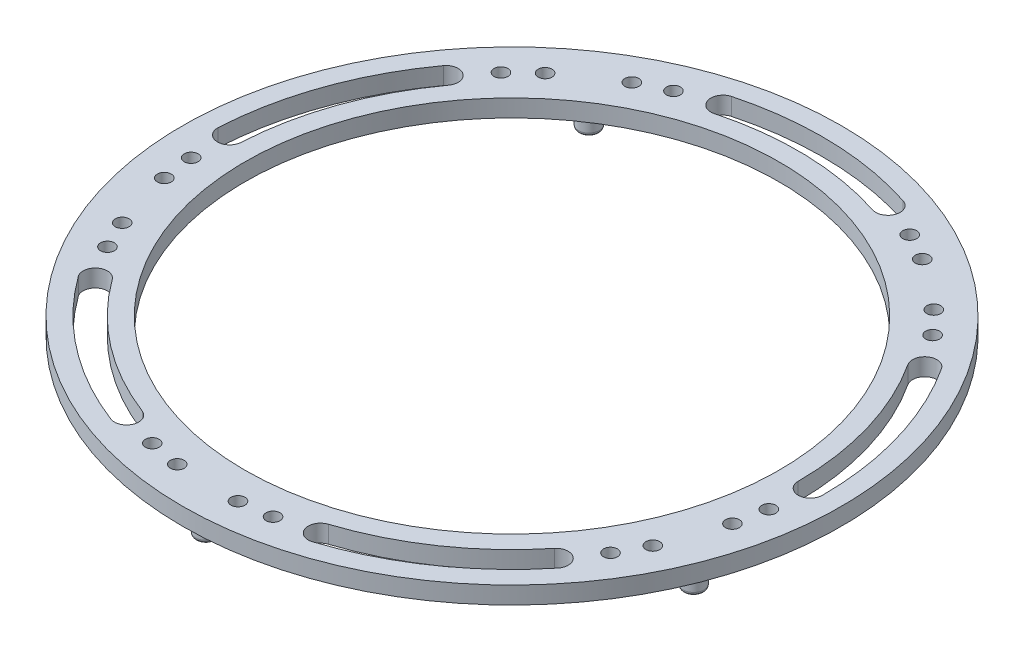
from build123d import *

# Parameters (mm, degrees)
SKETCH1_R                = 47.5
SKETCH1_R_2              = 38.5
BOSS_EXTRUDE1_DEPTH      = 2.5
SKETCH2_R                = 1.5
CUT_EXTRUDE1_DEPTH       = 2.5
SKETCH3_R                = 1.5
BOSS_EXTRUDE2_DEPTH      = 6.5
FILLET1_R                = 0.5
CIRPATTERN1_COUNT        = 5
FILLET1_OF_CIRPATTERN1_R = 0.5
SKETCH4_R                = 1
CUT_EXTRUDE2_DEPTH       = 2.5
CIRPATTERN2_COUNT        = 5


with BuildPart() as part:
    # Sketch1 → Boss-Extrude1 (new body)
    with BuildSketch(Plane(origin=(0, 0, 0), x_dir=(1, 0, 0), z_dir=(0, 1, 0))):
        Circle(SKETCH1_R)
        Circle(SKETCH1_R_2, mode=Mode.SUBTRACT)
    extrude(amount=BOSS_EXTRUDE1_DEPTH)

    # Sketch2 → Cut-Extrude1 (cut)
    with BuildSketch(Plane(origin=(0, 2.5, 0), x_dir=(1, 0, 0), z_dir=(0, 1, 0))):
        with Locations((26.176741447, 34.114193633)):
            Circle(SKETCH2_R)
        with BuildLine():
            ThreePointArc((44.75, 0), (42.907183135, 12.709686676), (37.530507916, 24.372596817))
            ThreePointArc((37.530507916, 24.372596817), (35.10971611, 24.887152), (34.595160928, 22.466360194))
            ThreePointArc((34.595160928, 22.466360194), (39.551314063, 11.715632969), (41.25, 0))
            ThreePointArc((41.25, 0), (43, -1.75), (44.75, 0))
        make_face()
    cut_extrude1 = extrude(amount=-CUT_EXTRUDE1_DEPTH, mode=Mode.SUBTRACT)

    # Sketch3 → Boss-Extrude2 (add)
    with BuildSketch(Plane(origin=(0, 2.5, 0), x_dir=(1, 0, 0), z_dir=(0, 1, 0))):
        with Locations((26.176741447, 34.114193633)):
            Circle(SKETCH3_R)
    boss_extrude2 = extrude(amount=-BOSS_EXTRUDE2_DEPTH)

    # Fillet1
    fillet1_edges = [part.edges().sort_by_distance(p)[0] for p in [
        (24.676741447, 0, -34.114193633),
        (24.676741447, -4, -34.114193633),
    ]]
    fillet(fillet1_edges, radius=FILLET1_R)

    # CirPattern1: Cut-Extrude1, Boss-Extrude2 ×5 about axis
    cirpattern1_axis = Axis((0, 0, 0), (0, 1, 0))
    for i in range(1, CIRPATTERN1_COUNT):
        add(cut_extrude1.rotate(cirpattern1_axis, i * 360 / CIRPATTERN1_COUNT), mode=Mode.SUBTRACT)
        add(boss_extrude2.rotate(cirpattern1_axis, i * 360 / CIRPATTERN1_COUNT))

    # Fillet1 of CirPattern1
    fillet1_of_cirpattern1_edges = [part.edges().sort_by_distance(p)[0] for p in [
        (-24.818993679, 0, -34.010841336),
        (-24.818993679, -4, -34.010841336),
        (-40.015723108, 0, 13.094337701),
        (-40.015723108, -4, 13.094337701),
        (0.087916714, 0, 42.103587096),
        (0.087916714, -4, 42.103587096),
        (40.070058625, 0, 12.927110173),
        (40.070058625, -4, 12.927110173),
    ]]
    fillet(fillet1_of_cirpattern1_edges, radius=FILLET1_OF_CIRPATTERN1_R)

    # Sketch4 → Cut-Extrude2 (cut)
    with BuildSketch(Plane.XZ):
        with Locations((-5.612626265, 42.632129039)):
            Circle(SKETCH4_R)
        with Locations((3.373741116, 42.867445351)):
            Circle(SKETCH4_R)
        with Locations((-10.038150646, 41.811906577)):
            Circle(SKETCH4_R)
        with Locations((7.836127596, 42.279961025)):
            Circle(SKETCH4_R)
    cut_extrude2 = extrude(amount=-CUT_EXTRUDE2_DEPTH, mode=Mode.SUBTRACT)

    # CirPattern2: Cut-Extrude2 ×5 about axis
    cirpattern2_axis = Axis((0, 0, 0), (0, 1, 0))
    for i in range(1, CIRPATTERN2_COUNT):
        add(cut_extrude2.rotate(cirpattern2_axis, i * 360 / CIRPATTERN2_COUNT), mode=Mode.SUBTRACT)


solid = part.part
